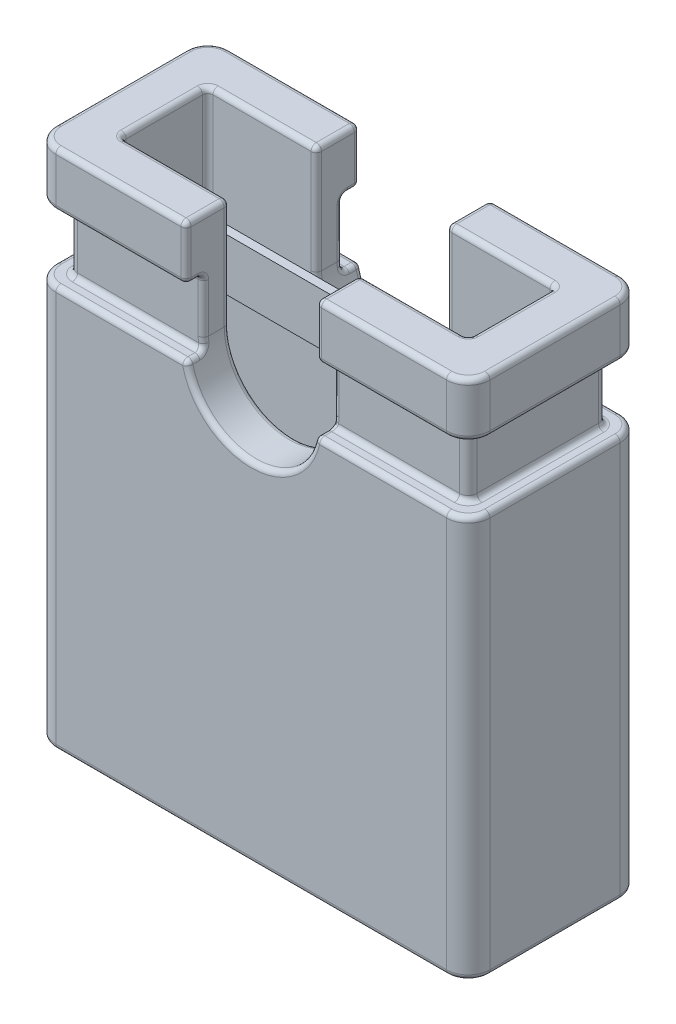
from build123d import *

# Parameters (mm, degrees)
BOSS_EXTRUDE1_DEPTH      = 1
BOSS_EXTRUDE1_DEPTH_BACK = 1
SKETCH2_W                = 4
SKETCH2_H                = 1
CUT_EXTRUDE1_DEPTH       = 8.5
CUT_EXTRUDE2_DEPTH       = 0.375
CUT_EXTRUDE2_DEPTH_BACK  = 0.375
SKETCH3_OUTSIDE_W        = 5.612
SKETCH3_OUTSIDE_H        = 8.612
FILLET1_R                = 0.25
FILLET2_R                = 0.06
FILLET3_R                = 0.06
FILLET4_R                = 0.06
BOSS_EXTRUDE2_DEPTH      = 2
BOSS_EXTRUDE2_DEPTH_BACK = 2
SKETCH4_W                = 0.6
SKETCH4_H                = 0.1


with BuildPart() as part:
    # Sketch1 → Boss-Extrude1 (new, two sides: drawn at the far end of the back side and taken through both)
    with BuildSketch(Plane.XY.offset(-BOSS_EXTRUDE1_DEPTH_BACK)):
        with BuildLine():
            Line((-2.5, 7), (-0.75, 7))
            Line((-0.75, 7), (-0.75, 5.75))
            ThreePointArc((-0.75, 5.75), (0, 5), (0.75, 5.75))
            Line((0.75, 5.75), (0.75, 7))
            Line((0.75, 7), (2.5, 7))
            Line((2.5, 7), (2.5, 1))
            Line((2.5, 1), (-2.5, 1))
            Line((-2.5, 1), (-2.5, 7))
        make_face()
    extrude(amount=BOSS_EXTRUDE1_DEPTH + BOSS_EXTRUDE1_DEPTH_BACK)

    # Sketch2 → Cut-Extrude1 (cut, through all)
    with BuildSketch(Plane.XZ):
        Rectangle(SKETCH2_W, SKETCH2_H)
    extrude(amount=-CUT_EXTRUDE1_DEPTH, mode=Mode.SUBTRACT)

    # Sketch3 outside → Cut-Extrude2 (cut, two sides: drawn at the far end of the back side and taken through both)
    with BuildSketch(Plane(origin=(0, 6, -1), x_dir=(0, 0, -1), z_dir=(0, 1, 0)).offset(-CUT_EXTRUDE2_DEPTH_BACK)):
        with Locations((-1, 0)):
            Rectangle(SKETCH3_OUTSIDE_W, SKETCH3_OUTSIDE_H)
        with BuildLine():
            Line((-1.7, 2.3), (-0.3, 2.3))
            ThreePointArc((-0.3, 2.3), (-0.229289322, 2.270710678), (-0.2, 2.2))
            Line((-0.2, 2.2), (-0.2, -2.2))
            ThreePointArc((-0.2, -2.2), (-0.229289322, -2.270710678), (-0.3, -2.3))
            Line((-0.3, -2.3), (-1.7, -2.3))
            ThreePointArc((-1.7, -2.3), (-1.770710678, -2.270710678), (-1.8, -2.2))
            Line((-1.8, -2.2), (-1.8, 2.2))
            ThreePointArc((-1.8, 2.2), (-1.770710678, 2.270710678), (-1.7, 2.3))
        make_face(mode=Mode.SUBTRACT)
    extrude(amount=CUT_EXTRUDE2_DEPTH + CUT_EXTRUDE2_DEPTH_BACK, mode=Mode.SUBTRACT)

    # Fillet1
    fillet1_edges = [part.edges().sort_by_distance(p)[0] for p in [
        (-2.5, 6.6875, -1),
        (-2.5, 3.3125, -1),
        (-2.5, 3.3125, 1),
        (-2.5, 6.6875, 1),
        (2.5, 6.6875, -1),
        (2.5, 3.3125, -1),
        (2.5, 3.3125, 1),
        (2.5, 6.6875, 1),
    ]]
    fillet(fillet1_edges, radius=FILLET1_R)

    # Fillet2
    fillet2_edges = [part.edges().sort_by_distance(p)[0] for p in [
        (1.475, 6.375, -0.8),
        (2.270710678, 6.375, -0.770710678),
        (2.3, 6.375, 0),
        (2.270710678, 6.375, 0.770710678),
        (1.475, 6.375, 0.8),
        (-1.5, 6.375, -1),
        (-2.426776695, 6.375, -0.926776695),
        (-2.5, 6.375, 0),
        (-2.426776695, 6.375, 0.926776695),
        (-1.5, 6.375, 1),
        (-1.494754986, 5.625, -1),
        (-2.426776695, 5.625, -0.926776695),
        (-2.5, 5.625, 0),
        (-2.426776695, 5.625, 0.926776695),
        (-1.494754986, 5.625, 1),
        (1.494754986, 5.625, -1),
        (2.426776695, 5.625, -0.926776695),
        (2.5, 5.625, 0),
        (2.426776695, 5.625, 0.926776695),
        (1.494754986, 5.625, 1),
        (2, 4, 0.5),
        (2, 4, -0.5),
        (-2, 4, 0.5),
        (-2, 4, -0.5),
        (1.5, 7, 1),
        (2.426776695, 7, 0.926776695),
        (2.5, 7, 0),
        (2.426776695, 7, -0.926776695),
        (1.5, 7, -1),
        (-1.5, 7, -1),
        (-2.426776695, 7, -0.926776695),
        (-2.5, 7, 0),
        (-2.426776695, 7, 0.926776695),
        (-1.5, 7, 1),
        (1.5, 6.375, -1),
        (2.426776695, 6.375, -0.926776695),
        (2.5, 6.375, 0),
        (2.426776695, 6.375, 0.926776695),
        (1.5, 6.375, 1),
        (-1.475, 6.375, -0.8),
        (-2.270710678, 6.375, -0.770710678),
        (-2.3, 6.375, 0),
        (-2.270710678, 6.375, 0.770710678),
        (-1.475, 6.375, 0.8),
        (-1.469754986, 5.625, -0.8),
        (-2.270710678, 5.625, -0.770710678),
        (-2.3, 5.625, 0),
        (-2.270710678, 5.625, 0.770710678),
        (-1.469754986, 5.625, 0.8),
        (1.469754986, 5.625, -0.8),
        (2.270710678, 5.625, -0.770710678),
        (2.3, 5.625, 0),
        (2.270710678, 5.625, 0.770710678),
        (1.469754986, 5.625, 0.8),
    ]]
    fillet(fillet2_edges, radius=FILLET2_R)

    # Fillet3
    fillet3_edges = [part.edges().sort_by_distance(p)[0] for p in [
        (1.345, 7, 0.5),
        (1.982426407, 7, 0.482426407),
        (2, 7, 0),
        (1.982426407, 7, -0.482426407),
        (1.345, 7, -0.5),
        (-1.345, 7, 0.5),
        (-1.982426407, 7, 0.482426407),
        (-2, 7, 0),
        (-1.982426407, 7, -0.482426407),
        (-1.345, 7, -0.5),
    ]]
    fillet(fillet3_edges, radius=FILLET3_R)

    # Fillet4
    fillet4_edges = [part.edges().sort_by_distance(p)[0] for p in [
        (2.5, 1, 0),
        (2.426776695, 1, -0.926776695),
        (0, 1, -1),
        (-2.426776695, 1, -0.926776695),
        (-2.5, 1, 0),
        (-2.426776695, 1, 0.926776695),
        (0, 1, 1),
        (2.426776695, 1, 0.926776695),
        (0, 5, -0.5),
        (0.75, 6.345, -0.5),
        (0.75, 6.982426407, -0.517573593),
        (0.75, 7, -0.75),
        (0.75, 6.982426407, -0.982426407),
        (0.75, 6.6875, -1),
        (0.75, 6.392573593, -0.982426407),
        (0.75, 6.375, -0.9),
        (0.75, 6.357426407, -0.817573593),
        (0.75, 6.0325, -0.8),
        (0.749294174, 5.717469385, -0.8),
        (0.742274345, 5.642627788, -0.817519468),
        (0.739509973, 5.625, -0.9),
        (0.736267243, 5.607134513, -0.982716304),
        (0, 5, -1),
        (-0.736267243, 5.607134513, -0.982716304),
        (-0.739509973, 5.625, -0.9),
        (-0.742274345, 5.642627788, -0.817519469),
        (-0.749294174, 5.717469385, -0.8),
        (-0.75, 6.0325, -0.8),
        (-0.75, 6.357426407, -0.817573593),
        (-0.75, 6.375, -0.9),
        (-0.75, 6.392573593, -0.982426407),
        (-0.75, 6.6875, -1),
        (-0.75, 6.982426407, -0.982426407),
        (-0.75, 7, -0.75),
        (-0.75, 6.982426407, -0.517573593),
        (-0.75, 6.345, -0.5),
        (0.736267243, 5.607134513, 0.982716304),
        (0.739509973, 5.625, 0.9),
        (0.742274345, 5.642627788, 0.817519468),
        (0.749294174, 5.717469385, 0.8),
        (0.75, 6.0325, 0.8),
        (0.75, 6.357426407, 0.817573593),
        (0.75, 6.375, 0.9),
        (0.75, 6.392573593, 0.982426407),
        (0.75, 6.6875, 1),
        (0.75, 6.982426407, 0.982426407),
        (0.75, 7, 0.75),
        (0.75, 6.982426407, 0.517573593),
        (0.75, 6.345, 0.5),
        (0, 5, 0.5),
        (-0.75, 6.345, 0.5),
        (-0.75, 6.982426407, 0.517573593),
        (-0.75, 7, 0.75),
        (-0.75, 6.982426407, 0.982426407),
        (-0.75, 6.6875, 1),
        (-0.75, 6.392573593, 0.982426407),
        (-0.75, 6.375, 0.9),
        (-0.75, 6.357426407, 0.817573593),
        (-0.75, 6.0325, 0.8),
        (-0.749294174, 5.717469385, 0.8),
        (-0.742274345, 5.642627788, 0.817519469),
        (-0.739509973, 5.625, 0.9),
        (-0.736267243, 5.607134513, 0.982716304),
        (0, 5, 1),
    ]]
    fillet(fillet4_edges, radius=FILLET4_R)

    # Sketch4 → Boss-Extrude2 (add, two sides: drawn at the far end of the back side and taken through both)
    with BuildSketch(Plane.YZ.offset(-BOSS_EXTRUDE2_DEPTH_BACK)):
        with Locations((6.3, 0.425)):
            Rectangle(SKETCH4_W, SKETCH4_H)
    extrude(amount=BOSS_EXTRUDE2_DEPTH + BOSS_EXTRUDE2_DEPTH_BACK)


solid = part.part
